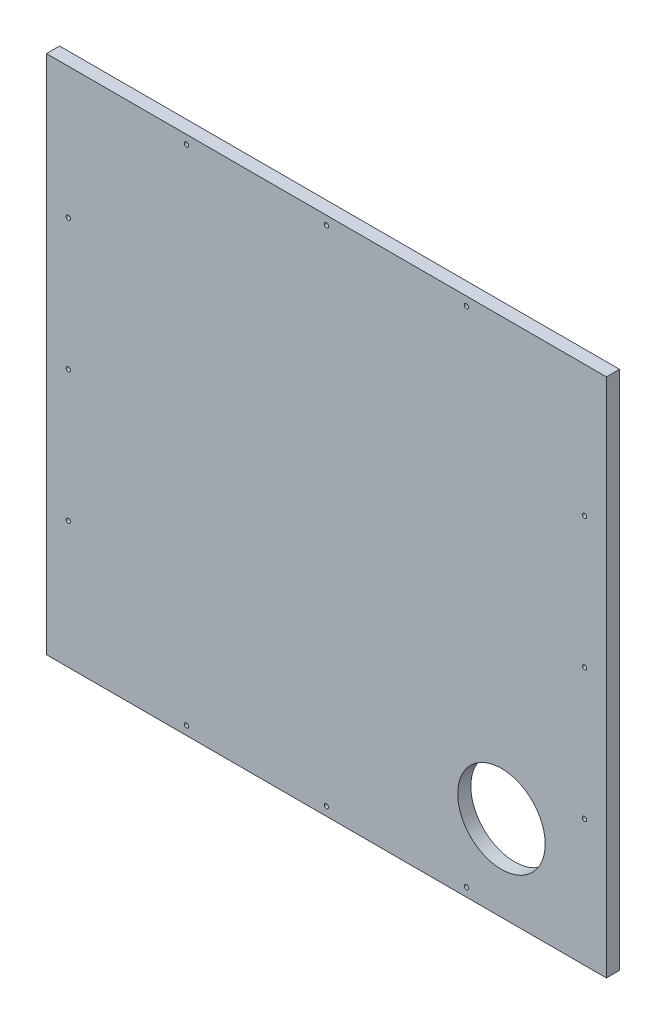
from build123d import *

# Parameters (mm, degrees)
SKETCH_1_W          = 640
SKETCH_1_H          = 595
EXTRUDE_1_DEPTH     = 15
SKETCH_2_R          = 2.5
CUT_EXTRUDE_1_DEPTH = 438.185601318
SKETCH_2_3_R        = 2.5
CUT_EXTRUDE_2_DEPTH = 438.185601318
SKETCH_3_R          = 50
CUT_EXTRUDE_3_DEPTH = 438.185601318


with BuildPart() as part:
    # ｽｹｯﾁ1 → ﾎﾞｽ - 押し出し1 (new body)
    with BuildSketch(Plane.XY):
        Rectangle(SKETCH_1_W, SKETCH_1_H)
    extrude(amount=EXTRUDE_1_DEPTH)

    # ｽｹｯﾁ2 → ｶｯﾄ - 押し出し1 (cut, through all)
    with BuildSketch(Plane.XY.offset(15)):
        with Locations((-160, 287.5)):
            Circle(SKETCH_2_R)
        with Locations((0, 287.5)):
            Circle(SKETCH_2_R)
        with Locations((160, 287.5)):
            Circle(SKETCH_2_R)
    cut_extrude_1 = extrude(amount=-CUT_EXTRUDE_1_DEPTH, mode=Mode.SUBTRACT)

    # ｽｹｯﾁ2<3> → ｶｯﾄ - 押し出し2 (cut, through all)
    with BuildSketch(Plane.XY.offset(15)):
        with Locations((-295, 147.5)):
            Circle(SKETCH_2_3_R)
        with Locations((-295, -2.5)):
            Circle(SKETCH_2_3_R)
        with Locations((-295, -152.5)):
            Circle(SKETCH_2_3_R)
    cut_extrude_2 = extrude(amount=-CUT_EXTRUDE_2_DEPTH, mode=Mode.SUBTRACT)

    # ﾐﾗｰ1: ｶｯﾄ - 押し出し1 across plane
    add(cut_extrude_1.mirror(Plane.ZX), mode=Mode.SUBTRACT)

    # ﾐﾗｰ2: ｶｯﾄ - 押し出し2 across plane
    add(cut_extrude_2.mirror(Plane(origin=(0, 0, 0), x_dir=(0, 0, 1), z_dir=(1, 0, 0))), mode=Mode.SUBTRACT)

    # ｽｹｯﾁ3 → ｶｯﾄ - 押し出し3 (cut, through all)
    with BuildSketch(Plane.XY.offset(15)):
        with Locations((200, -200)):
            Circle(SKETCH_3_R)
    extrude(amount=-CUT_EXTRUDE_3_DEPTH, mode=Mode.SUBTRACT)


solid = part.part
